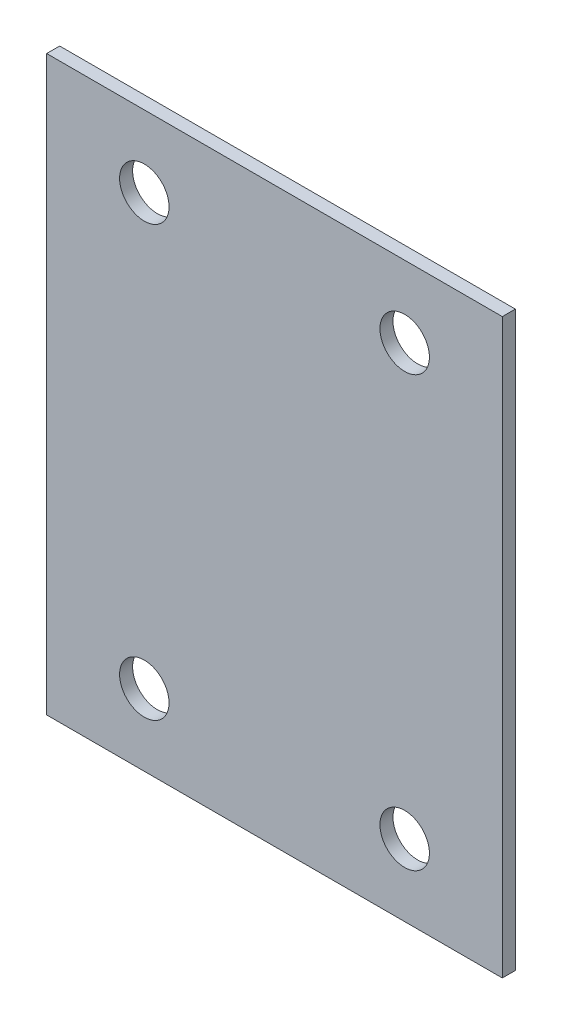
from build123d import *

# Parameters (mm, degrees)
SKETCH_1_W      = 350
SKETCH_1_H      = 440
SKETCH_1_R      = 19
EXTRUDE_1_DEPTH = 10


with BuildPart() as part:
    # Эскиз1 → Бобышка-Вытянуть1 (new body)
    with BuildSketch(Plane.XY):
        Rectangle(SKETCH_1_W, SKETCH_1_H)
        with Locations((-100, 165)):
            Circle(SKETCH_1_R, mode=Mode.SUBTRACT)
        with Locations((100, 165)):
            Circle(SKETCH_1_R, mode=Mode.SUBTRACT)
        with Locations((100, -165)):
            Circle(SKETCH_1_R, mode=Mode.SUBTRACT)
        with Locations((-100, -165)):
            Circle(SKETCH_1_R, mode=Mode.SUBTRACT)
    extrude(amount=EXTRUDE_1_DEPTH)


solid = part.part
